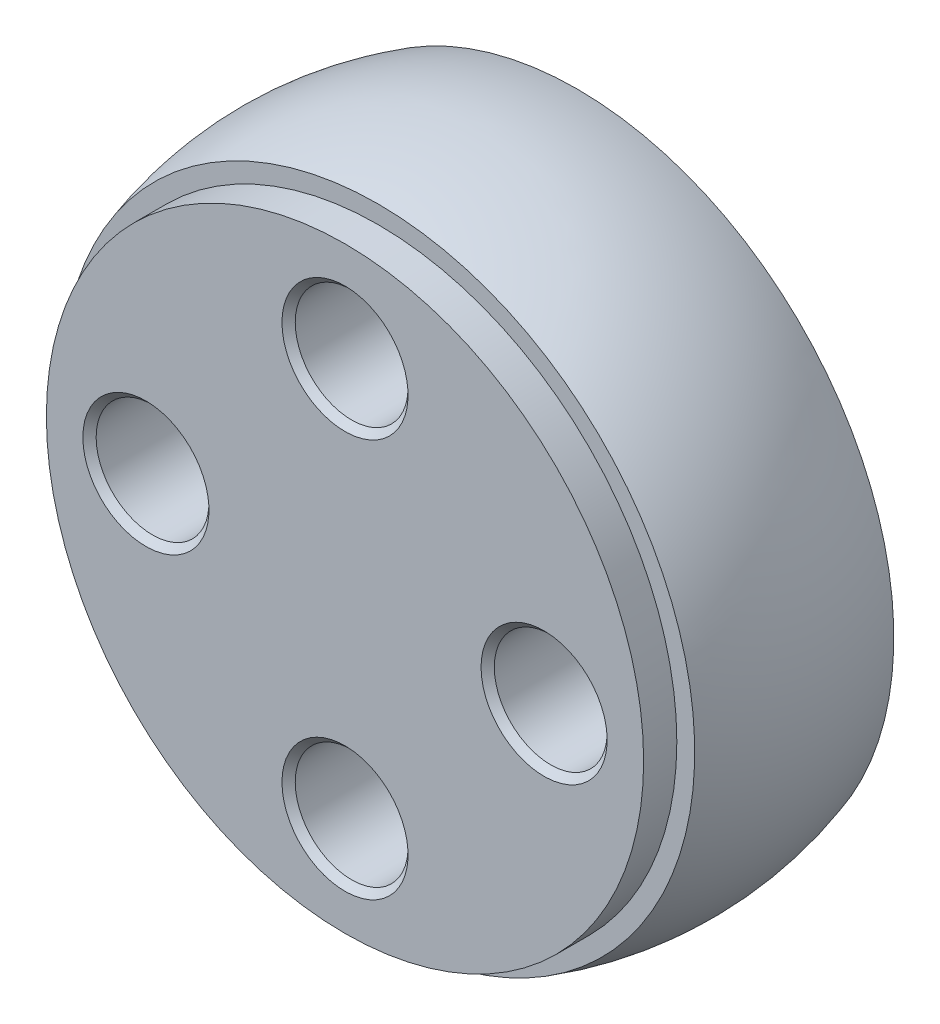
from build123d import *

# Parameters (mm, degrees)
HOLE_WIZARD_M31_AT_2_COUNT = 2
HOLE_WIZARD_M31_AT_2_PITCH = 12
HOLE_WIZARD_M31_AT_3_COUNT = 2
HOLE_WIZARD_M31_AT_3_PITCH = 8.485281374
HOLE_WIZARD_M31_AT_4_COUNT = 2
HOLE_WIZARD_M31_AT_4_PITCH = 8.485281374


with BuildPart() as part:
    # Эскиз1 → Повернуть1 (revolve)
    with BuildSketch(Plane(origin=(0, 0, 0), x_dir=(0, 0, -1), z_dir=(1, 0, 0))):
        with BuildLine():
            Line((-4, 9), (-3, 9))
            Line((-3, 9), (-3, 9.539392014))
            ThreePointArc((-3, 9.539392014), (0, 10), (3, 9.539392014))
            Line((3, 9.539392014), (3, 0))
            Line((3, 0), (-4, 0))
            Line((-4, 0), (-4, 9))
        make_face()
    revolve(axis=Axis((0, 0, 0), (0, 0, 1)))

    # Эскиз2 → Цековка для винта с внутренним шестигранником M31 (revolve, cut)
    with BuildSketch(Plane(origin=(6, 0, -3), x_dir=(0, 1, 0), z_dir=(1, 0, 0))):
        Polygon((0, 0), (0, 7), (1.9, 7), (1.7, 6.8), (1.7, 3.6), (1.9, 3.4), (3, 3.4), (3, 0.25), (3.25, 0), align=None)
    hole_wizard_m31 = revolve(axis=Axis((6, 0, -9.35), (0, 0, 1)), mode=Mode.SUBTRACT)

    # Цековка для винта с внутренним шестигранником M31 at 2: Цековка для винта с внутренним шестигранником M31 ×2
    with Locations(*[(-i * HOLE_WIZARD_M31_AT_2_PITCH, 0, 0) for i in range(1, HOLE_WIZARD_M31_AT_2_COUNT)]):
        add(hole_wizard_m31, mode=Mode.SUBTRACT)

    # Цековка для винта с внутренним шестигранником M31 at 3: Цековка для винта с внутренним шестигранником M31 ×2
    with Locations(*[Vector(-0.707106781, 0.707106781, 0) * (i * HOLE_WIZARD_M31_AT_3_PITCH) for i in range(1, HOLE_WIZARD_M31_AT_3_COUNT)]):
        add(hole_wizard_m31, mode=Mode.SUBTRACT)

    # Цековка для винта с внутренним шестигранником M31 at 4: Цековка для винта с внутренним шестигранником M31 ×2
    with Locations(*[Vector(-0.707106781, -0.707106781, 0) * (i * HOLE_WIZARD_M31_AT_4_PITCH) for i in range(1, HOLE_WIZARD_M31_AT_4_COUNT)]):
        add(hole_wizard_m31, mode=Mode.SUBTRACT)


solid = part.part
